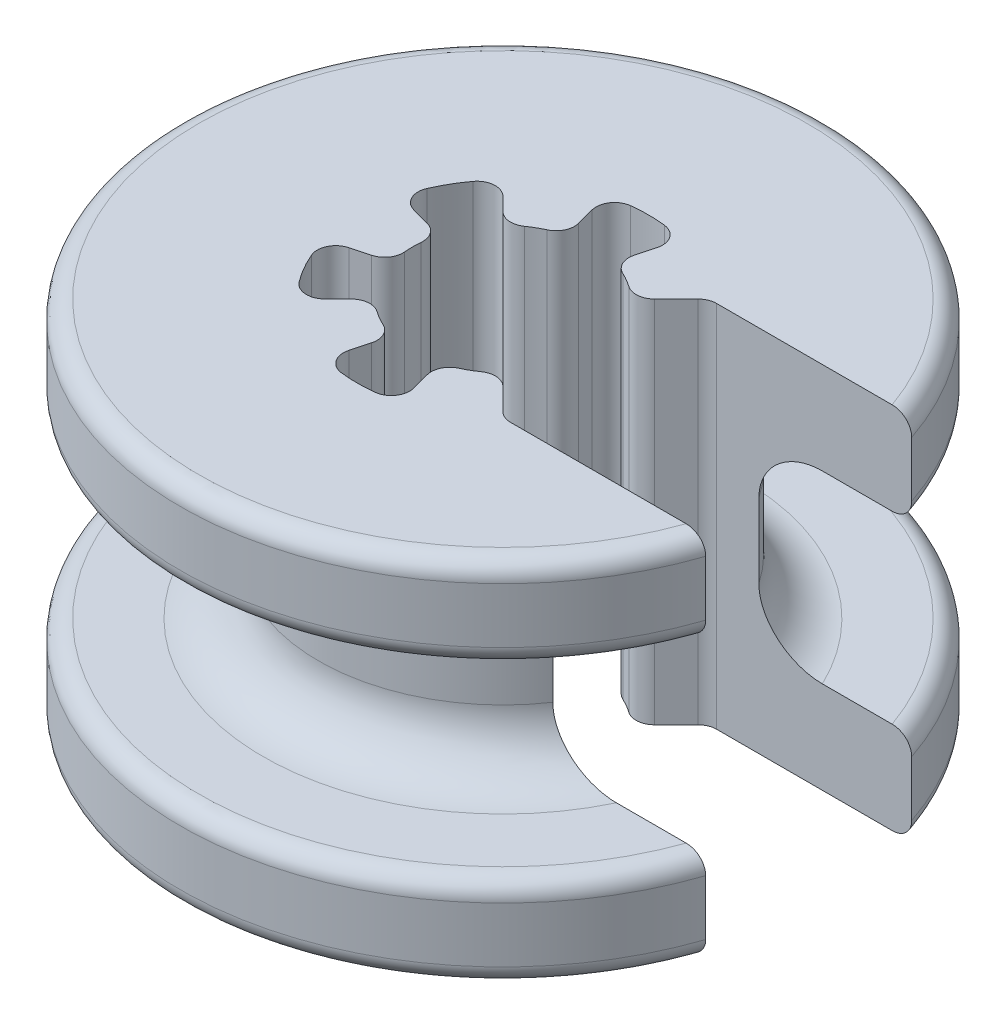
from build123d import *

# Parameters (mm, degrees)
BOSS_EXTRUDE1_DEPTH = 2.5
BOSS_EXTRUDE2_DEPTH = 5
BOSS_EXTRUDE3_DEPTH = 2.5
FILLET1_R           = 0.5
FILLET2_R           = 1.5
FILLET3_R           = 0.5


with BuildPart() as part:
    # Sketch1 → Boss-Extrude1 (new body)
    with BuildSketch(Plane(origin=(0, 0, 0), x_dir=(1, 0, 0), z_dir=(0, 1, 0))):
        with BuildLine():
            Line((2.793071786, 2.793071786), (8.292240349, 2.793071786))
            ThreePointArc((8.292240349, 2.793071786), (-8.75, 0), (8.292240349, -2.793071786))
            Line((8.292240349, -2.793071786), (2.793071786, -2.793071786))
            Line((2.793071786, -2.793071786), (1.732411614, -1.732411614))
            ThreePointArc((1.732411614, -1.732411614), (1.225, -2.121762239), (0.634106661, -2.366518274))
            Line((0.634106661, -2.366518274), (1.022335228, -3.815407014))
            ThreePointArc((1.022335228, -3.815407014), (0, -3.95), (-1.022335228, -3.815407014))
            Line((-1.022335228, -3.815407014), (-0.634106661, -2.366518274))
            ThreePointArc((-0.634106661, -2.366518274), (-1.225, -2.121762239), (-1.732411614, -1.732411614))
            Line((-1.732411614, -1.732411614), (-2.793071786, -2.793071786))
            ThreePointArc((-2.793071786, -2.793071786), (-3.420800345, -1.975), (-3.815407014, -1.022335228))
            Line((-3.815407014, -1.022335228), (-2.366518274, -0.634106661))
            ThreePointArc((-2.366518274, -0.634106661), (-2.45, 0), (-2.366518274, 0.634106661))
            Line((-2.366518274, 0.634106661), (-3.815407014, 1.022335228))
            ThreePointArc((-3.815407014, 1.022335228), (-3.420800345, 1.975), (-2.793071786, 2.793071786))
            Line((-2.793071786, 2.793071786), (-1.732411614, 1.732411614))
            ThreePointArc((-1.732411614, 1.732411614), (-1.225, 2.121762239), (-0.634106661, 2.366518274))
            Line((-0.634106661, 2.366518274), (-1.022335228, 3.815407014))
            ThreePointArc((-1.022335228, 3.815407014), (0, 3.95), (1.022335228, 3.815407014))
            Line((1.022335228, 3.815407014), (0.634106661, 2.366518274))
            ThreePointArc((0.634106661, 2.366518274), (1.225, 2.121762239), (1.732411614, 1.732411614))
            Line((1.732411614, 1.732411614), (2.793071786, 2.793071786))
        make_face()
    extrude(amount=BOSS_EXTRUDE1_DEPTH)

    # Sketch3 → Boss-Extrude2 (add)
    with BuildSketch(Plane(origin=(0, 2.5, 0), x_dir=(1, 0, 0), z_dir=(0, 1, 0))):
        with BuildLine():
            Line((2.793071786, 2.793071786), (4.147137567, 2.793071786))
            ThreePointArc((4.147137567, 2.793071786), (-5, 0), (4.147137567, -2.793071786))
            Line((4.147137567, -2.793071786), (2.793071786, -2.793071786))
            Line((2.793071786, -2.793071786), (1.732411614, -1.732411614))
            ThreePointArc((1.732411614, -1.732411614), (1.225, -2.121762239), (0.634106661, -2.366518274))
            Line((0.634106661, -2.366518274), (1.022335228, -3.815407014))
            ThreePointArc((1.022335228, -3.815407014), (0, -3.95), (-1.022335228, -3.815407014))
            Line((-1.022335228, -3.815407014), (-0.634106661, -2.366518274))
            ThreePointArc((-0.634106661, -2.366518274), (-1.225, -2.121762239), (-1.732411614, -1.732411614))
            Line((-1.732411614, -1.732411614), (-2.793071786, -2.793071786))
            ThreePointArc((-2.793071786, -2.793071786), (-3.420800345, -1.975), (-3.815407014, -1.022335228))
            Line((-3.815407014, -1.022335228), (-2.366518274, -0.634106661))
            ThreePointArc((-2.366518274, -0.634106661), (-2.45, 0), (-2.366518274, 0.634106661))
            Line((-2.366518274, 0.634106661), (-3.815407014, 1.022335228))
            ThreePointArc((-3.815407014, 1.022335228), (-3.420800345, 1.975), (-2.793071786, 2.793071786))
            Line((-2.793071786, 2.793071786), (-1.732411614, 1.732411614))
            ThreePointArc((-1.732411614, 1.732411614), (-1.225, 2.121762239), (-0.634106661, 2.366518274))
            Line((-0.634106661, 2.366518274), (-1.022335228, 3.815407014))
            ThreePointArc((-1.022335228, 3.815407014), (0, 3.95), (1.022335228, 3.815407014))
            Line((1.022335228, 3.815407014), (0.634106661, 2.366518274))
            ThreePointArc((0.634106661, 2.366518274), (1.225, 2.121762239), (1.732411614, 1.732411614))
            Line((1.732411614, 1.732411614), (2.793071786, 2.793071786))
        make_face()
    extrude(amount=BOSS_EXTRUDE2_DEPTH)

    # Sketch4 → Boss-Extrude3 (add)
    with BuildSketch(Plane(origin=(0, 7.5, 0), x_dir=(1, 0, 0), z_dir=(0, 1, 0))):
        with BuildLine():
            Line((1.732411614, 1.732411614), (2.793071786, 2.793071786))
            Line((2.793071786, 2.793071786), (8.292240349, 2.793071786))
            ThreePointArc((8.292240349, 2.793071786), (-8.75, 0), (8.292240349, -2.793071786))
            Line((8.292240349, -2.793071786), (2.793071786, -2.793071786))
            Line((2.793071786, -2.793071786), (1.732411614, -1.732411614))
            ThreePointArc((1.732411614, -1.732411614), (1.225, -2.121762239), (0.634106661, -2.366518274))
            Line((0.634106661, -2.366518274), (1.022335228, -3.815407014))
            ThreePointArc((1.022335228, -3.815407014), (0, -3.95), (-1.022335228, -3.815407014))
            Line((-1.022335228, -3.815407014), (-0.634106661, -2.366518274))
            ThreePointArc((-0.634106661, -2.366518274), (-1.225, -2.121762239), (-1.732411614, -1.732411614))
            Line((-1.732411614, -1.732411614), (-2.793071786, -2.793071786))
            ThreePointArc((-2.793071786, -2.793071786), (-3.420800345, -1.975), (-3.815407014, -1.022335228))
            Line((-3.815407014, -1.022335228), (-2.366518274, -0.634106661))
            ThreePointArc((-2.366518274, -0.634106661), (-2.45, 0), (-2.366518274, 0.634106661))
            Line((-2.366518274, 0.634106661), (-3.815407014, 1.022335228))
            ThreePointArc((-3.815407014, 1.022335228), (-3.420800345, 1.975), (-2.793071786, 2.793071786))
            Line((-2.793071786, 2.793071786), (-1.732411614, 1.732411614))
            ThreePointArc((-1.732411614, 1.732411614), (-1.225, 2.121762239), (-0.634106661, 2.366518274))
            Line((-0.634106661, 2.366518274), (-1.022335228, 3.815407014))
            ThreePointArc((-1.022335228, 3.815407014), (0, 3.95), (1.022335228, 3.815407014))
            Line((1.022335228, 3.815407014), (0.634106661, 2.366518274))
            ThreePointArc((0.634106661, 2.366518274), (1.225, 2.121762239), (1.732411614, 1.732411614))
        make_face()
    extrude(amount=BOSS_EXTRUDE3_DEPTH)

    # Fillet1
    fillet1_edges = [part.edges().sort_by_distance(p)[0] for p in [
        (-1.732411614, 5, -1.732411614),
        (-2.793071786, 5, -2.793071786),
        (-3.815407014, 5, -1.022335228),
        (-2.366518274, 5, -0.634106661),
        (-2.366518274, 5, 0.634106661),
        (-3.815407014, 5, 1.022335228),
        (-2.793071786, 5, 2.793071786),
        (-1.732411614, 5, 1.732411614),
        (-0.634106661, 5, 2.366518274),
        (-1.022335228, 5, 3.815407014),
        (1.022335228, 5, 3.815407014),
        (0.634106661, 5, 2.366518274),
        (1.732411614, 5, 1.732411614),
        (2.793071786, 5, 2.793071786),
        (2.793071786, 5, -2.793071786),
        (1.732411614, 5, -1.732411614),
        (0.634106661, 5, -2.366518274),
        (1.022335228, 5, -3.815407014),
        (-1.022335228, 5, -3.815407014),
        (-0.634106661, 5, -2.366518274),
    ]]
    fillet(fillet1_edges, radius=FILLET1_R)

    # Fillet2
    fillet2_edges = [part.edges().sort_by_distance(p)[0] for p in [
        (-5, 2.5, 0),
        (-5, 7.5, 0),
    ]]
    fillet(fillet2_edges, radius=FILLET2_R)

    # Fillet3
    fillet3_edges = [part.edges().sort_by_distance(p)[0] for p in [
        (-8.75, 7.5, 0),
        (-8.75, 10, 0),
        (-8.75, 0, 0),
        (-8.75, 2.5, 0),
    ]]
    fillet(fillet3_edges, radius=FILLET3_R)


solid = part.part
